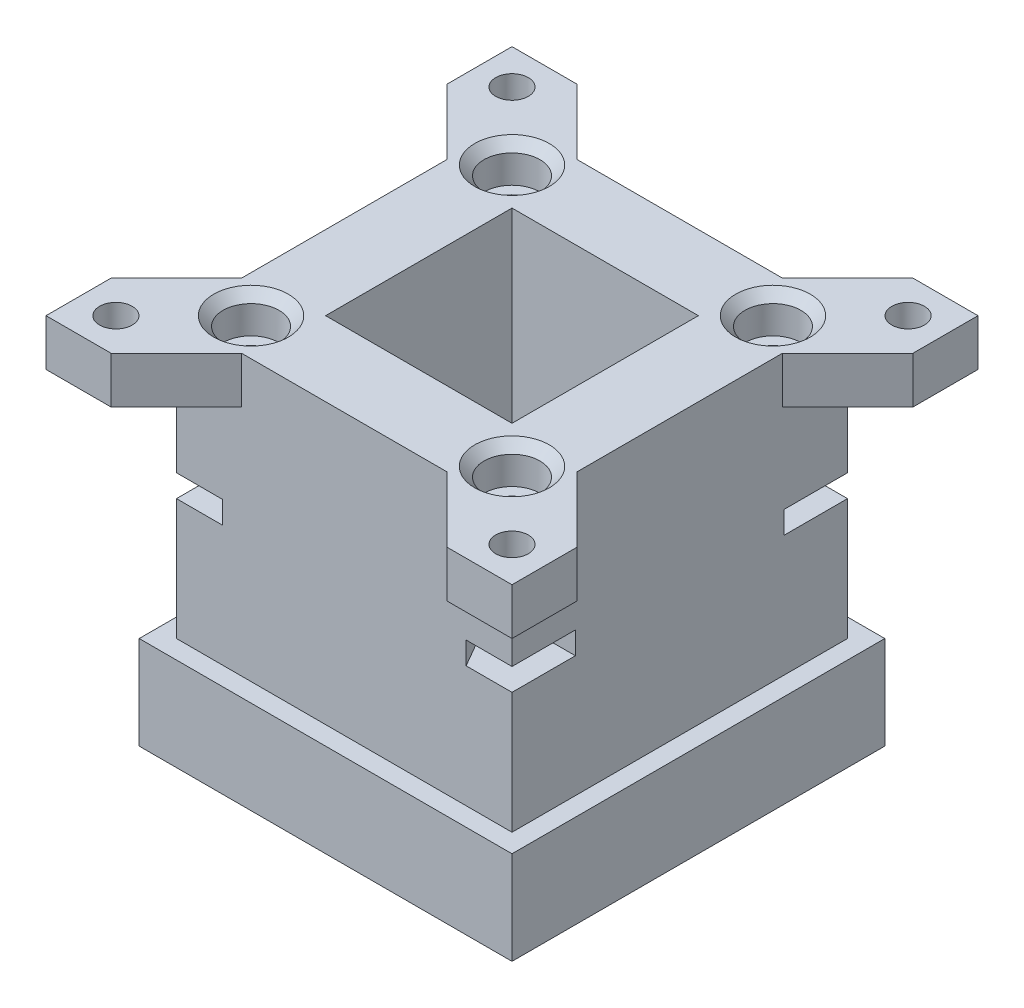
from build123d import *

# Parameters (mm, degrees)
SKETCH1_W           = 36
SKETCH1_H           = 36
SKETCH1_W_2         = 20
SKETCH1_H_2         = 20
BOSS_EXTRUDE4_DEPTH = 35
SKETCH9_W           = 50
SKETCH9_H           = 50
SKETCH9_W_2         = 22
SKETCH9_H_2         = 22
BOSS_EXTRUDE6_DEPTH = 5
SKETCH10_R          = 1.75
CUT_EXTRUDE2_DEPTH  = 10
CUT_EXTRUDE3_DEPTH  = 10
SKETCH4_W           = 40
SKETCH4_H           = 40
BOSS_EXTRUDE7_DEPTH = 10
SKETCH12_R          = 3
CUT_EXTRUDE4_DEPTH  = 4
CHAMFER1_SIZE       = 1
SKETCH13_R          = 1.75
CUT_EXTRUDE5_DEPTH  = 13
CUT_EXTRUDE7_DEPTH  = 2.4


with BuildPart() as part:
    # Sketch1 → Boss-Extrude4 (new body)
    with BuildSketch(Plane(origin=(0, 0, 0), x_dir=(1, 0, 0), z_dir=(0, 1, 0))):
        Rectangle(SKETCH1_W, SKETCH1_H)
        Rectangle(SKETCH1_W_2, SKETCH1_H_2, mode=Mode.SUBTRACT)
    extrude(amount=BOSS_EXTRUDE4_DEPTH)

    # Sketch9 → Boss-Extrude6 (add)
    with BuildSketch(Plane(origin=(0, 30, 0), x_dir=(1, 0, 0), z_dir=(0, 1, 0))):
        Rectangle(SKETCH9_W, SKETCH9_H)
        Rectangle(SKETCH9_W_2, SKETCH9_H_2, mode=Mode.SUBTRACT)
    extrude(amount=BOSS_EXTRUDE6_DEPTH)

    # Sketch10 → Cut-Extrude2 (cut)
    with BuildSketch(Plane(origin=(0, 25, 0), x_dir=(1, 0, 0), z_dir=(0, 1, 0))):
        with Locations((-21.25, 21.25)):
            Circle(SKETCH10_R)
        with Locations((21.25, 21.25)):
            Circle(SKETCH10_R)
        with Locations((21.25, -21.25)):
            Circle(SKETCH10_R)
        with Locations((-21.25, -21.25)):
            Circle(SKETCH10_R)
    extrude(amount=CUT_EXTRUDE2_DEPTH, mode=Mode.SUBTRACT)

    # Sketch11 → Cut-Extrude3 (cut)
    with BuildSketch(Plane(origin=(0, 25, 0), x_dir=(1, 0, 0), z_dir=(0, 1, 0))):
        Polygon((11, 18), (-11, 18), (-18, 25), (18, 25), align=None)
        Polygon((18, 11), (18, -11), (25, -18), (25, 18), align=None)
        Polygon((11, -18), (-11, -18), (-18, -25), (18, -25), align=None)
        Polygon((-18, 11), (-18, -11), (-25, -18), (-25, 18), align=None)
    extrude(amount=CUT_EXTRUDE3_DEPTH, mode=Mode.SUBTRACT)

    # Sketch4 → Boss-Extrude7 (add)
    with BuildSketch(Plane(origin=(0, -5, 0), x_dir=(1, 0, 0), z_dir=(0, 1, 0))):
        Rectangle(SKETCH4_W, SKETCH4_H)
        Polygon((-2.5, -8.548100716), (-2.5, -10), (-10, -10), (-10, -2.5), (-8.422351936, -2.5), (-4.844140472, -8.569430344), align=None, mode=Mode.SUBTRACT)
        Polygon((7.534421013, 0), (3.767210506, 6.525), (-3.767210506, 6.525), (-7.534421013, 0), (-3.767210506, -6.525), (3.767210506, -6.525), align=None, mode=Mode.SUBTRACT)
        Polygon((10, 10), (2.5, 10), (2.5, 8.548100716), (4.844140472, 8.569430344), (8.422351936, 2.5), (10, 2.5), align=None, mode=Mode.SUBTRACT)
        Polygon((10, -10), (2.5, -10), (2.5, -8.502605089), (4.999274138, -8.47986388), (8.379580585, -2.5), (10, -2.5), align=None, mode=Mode.SUBTRACT)
        Polygon((-10, 10), (-10, 2.5), (-8.379580585, 2.5), (-4.999274138, 8.47986388), (-2.5, 8.502605089), (-2.5, 10), align=None, mode=Mode.SUBTRACT)
    extrude(amount=BOSS_EXTRUDE7_DEPTH)

    # Sketch12 → Cut-Extrude4 (cut)
    with BuildSketch(Plane(origin=(0, 35, 0), x_dir=(1, 0, 0), z_dir=(0, 1, 0))):
        with Locations((-14, 14)):
            Circle(SKETCH12_R)
        with Locations((14, 14)):
            Circle(SKETCH12_R)
        with Locations((-14, -14)):
            Circle(SKETCH12_R)
        with Locations((14, -14)):
            Circle(SKETCH12_R)
    extrude(amount=-CUT_EXTRUDE4_DEPTH, mode=Mode.SUBTRACT)

    # Chamfer1
    chamfer1_edges = [part.edges().sort_by_distance(p)[0] for p in [
        (11, 35, -14),
        (-17, 35, 14),
        (11, 35, 14),
        (-17, 35, -14),
    ]]
    chamfer(chamfer1_edges, length=CHAMFER1_SIZE)

    # Sketch13 → Cut-Extrude5 (cut)
    with BuildSketch(Plane(origin=(0, 31, 0), x_dir=(1, 0, 0), z_dir=(0, 1, 0))):
        with Locations((-14, 14)):
            Circle(SKETCH13_R)
        with Locations((14, 14)):
            Circle(SKETCH13_R)
        with Locations((14, -14)):
            Circle(SKETCH13_R)
        with Locations((-14, -14)):
            Circle(SKETCH13_R)
    extrude(amount=-CUT_EXTRUDE5_DEPTH, mode=Mode.SUBTRACT)

    # Sketch15 → Cut-Extrude7 (cut)
    with BuildSketch(Plane(origin=(0, 18, 0), x_dir=(1, 0, 0), z_dir=(0, 1, 0))):
        Polygon((-10.766838493, 14), (-12.383419246, 16.8), (-15.581535205, 22.339299329), (-24.484943605, 19.967960566), (-22.149680093, 11.2), (-15.616580754, 11.2), (-12.383419246, 11.2), align=None)
        Polygon((15.616580754, 11.2), (12.383419246, 11.2), (10.766838493, 14), (12.383419246, 16.8), (15.581535205, 22.339299329), (24.484943605, 19.967960566), (22.149680093, 11.2), align=None)
        Polygon((15.616580754, -11.2), (12.383419246, -11.2), (10.766838493, -14), (12.383419246, -16.8), (15.581535205, -22.339299329), (24.484943605, -19.967960566), (22.149680093, -11.2), align=None)
        Polygon((-15.616580754, -11.2), (-12.383419246, -11.2), (-10.766838493, -14), (-12.383419246, -16.8), (-15.581535205, -22.339299329), (-24.484943605, -19.967960566), (-22.149680093, -11.2), align=None)
    extrude(amount=CUT_EXTRUDE7_DEPTH, mode=Mode.SUBTRACT)


solid = part.part
